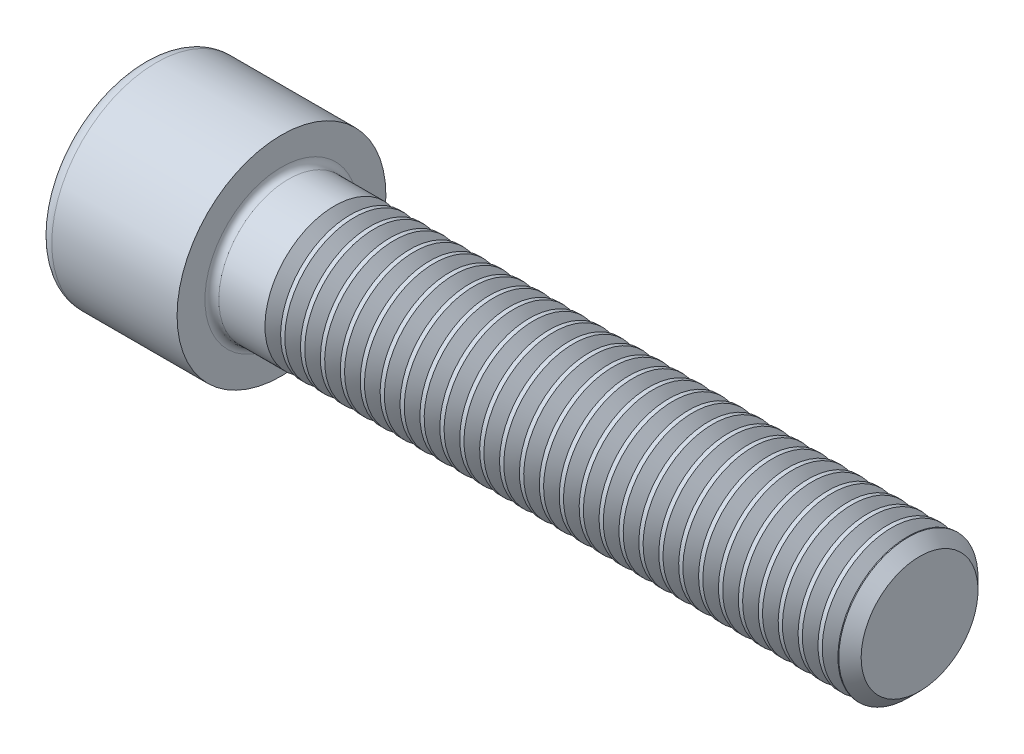
from build123d import *

# Parameters (mm, degrees)
FILLET1_R       = 0.6
FILLET2_R       = 1.2
HEX_2_DEPTH     = 6
THDSCHPAT_COUNT = 29
THDSCHPAT_PITCH = 1.715517241


with BuildPart() as part:
    # BodySke → Base-Revolve (revolve)
    with BuildSketch(Plane.XY, mode=Mode.PRIVATE) as base_revolve_sk:
        Polygon((0, 0), (0, 9), (12, 9), (12, 6), (66.036, 6), (67, 5.036), (67, 0), align=None)
    revolve(base_revolve_sk.sketch.rotate(Axis((-31.75, 0, 0), (1, 0, 0)), 90), axis=Axis((-31.75, 0, 0), (1, 0, 0)))  # turned: the seam where the file's is

    # Fillet1
    fillet1_edges = [part.edges().sort_by_distance(p)[0] for p in [
        (12, 0, -6),
    ]]
    fillet(fillet1_edges, radius=FILLET1_R)

    # Fillet2
    fillet2_edges = [part.edges().sort_by_distance(p)[0] for p in [
        (0, 0, -9),
    ]]
    fillet(fillet2_edges, radius=FILLET2_R)

    # Sketch2 → Hex-PreBroach (revolve, cut)
    with BuildSketch(Plane.XY, mode=Mode.PRIVATE) as hex_prebroach_sk:
        Polygon((0, 5.0125), (6, 5.0125), (8.893968224, 0), (0, 0), align=None)
    revolve(hex_prebroach_sk.sketch.rotate(Axis((0, 0, 0), (1, 0, 0)), 90), axis=Axis((0, 0, 0), (1, 0, 0)), mode=Mode.SUBTRACT)  # turned: the seam where the file's is

    # Sketch3 → Hex 2 (cut)
    with BuildSketch(Plane(origin=(0, 0, 0), x_dir=(0, 0.5, 0.866025404), z_dir=(-1, 0, 0))):
        Polygon((2.893968224, 5.0125), (-2.893968224, 5.0125), (-5.787936449, 0), (-2.893968224, -5.0125), (2.893968224, -5.0125), (5.787936449, 0), align=None)
    extrude(amount=-HEX_2_DEPTH, mode=Mode.SUBTRACT)

    # ThdSchSke → ThreadSchematic (revolve, cut)
    with BuildSketch(Plane.XY, mode=Mode.PRIVATE) as threadschematic_sk:
        Polygon((17.25, -5.036), (16.574999933, -6), (16.574999933, -7.5), (17.925000067, -7.5), (17.925000067, -6), align=None)
    threadschematic = revolve(threadschematic_sk.sketch.rotate(Axis((-3.175, 0, 0), (1, 0, 0)), 270), axis=Axis((-3.175, 0, 0), (1, 0, 0)), mode=Mode.SUBTRACT)  # turned: the seam where the file's is

    # ThdSchPat: ThreadSchematic ×29
    with Locations(*[(i * THDSCHPAT_PITCH, 0, 0) for i in range(1, THDSCHPAT_COUNT)]):
        add(threadschematic, mode=Mode.SUBTRACT)


solid = part.part
